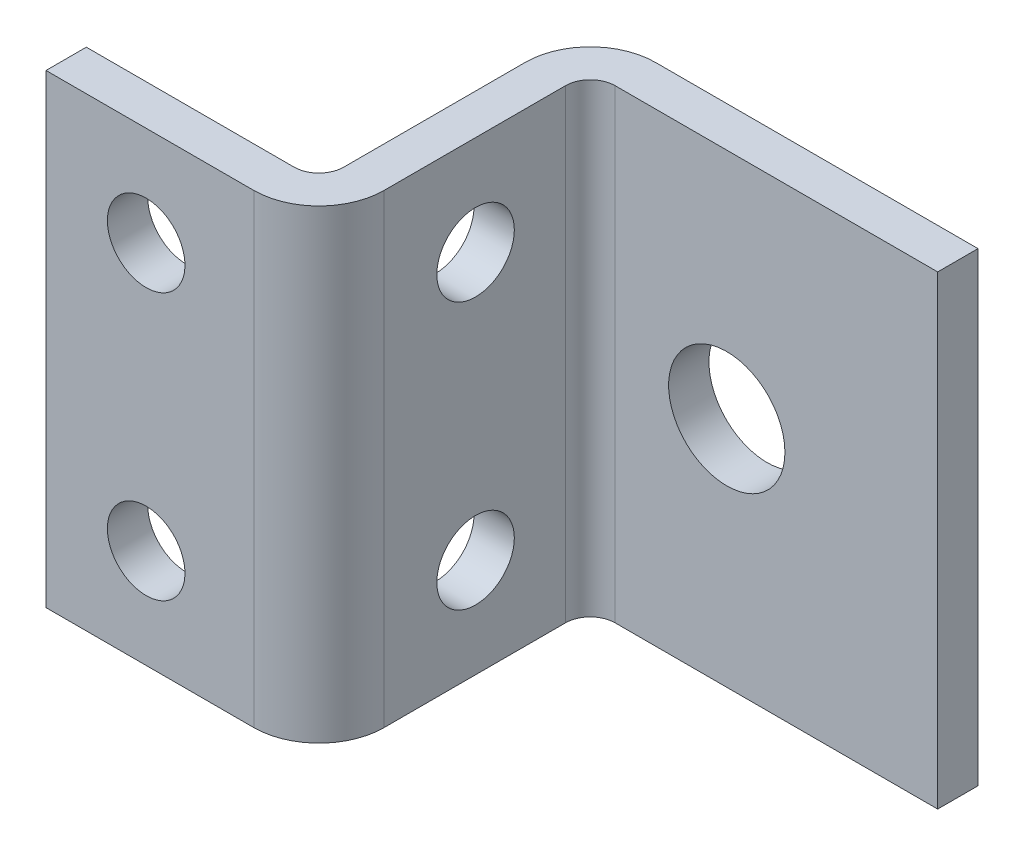
from build123d import *

# Parameters (mm, degrees)
EXTRUDE_THIN1_DEPTH = 19.05
SKETCH4_R           = 3.175
EXTRUDE3_DEPTH      = 26.527
SKETCH9_R           = 3.175
CUT_EXTRUDE3_DEPTH  = 23.352
SKETCH8_R           = 4.7625
CUT_EXTRUDE2_DEPTH  = 4.302


with BuildPart() as part:
    # Sketch1 → Extrude-Thin1 (new body, symmetric)
    with BuildSketch(Plane(origin=(0, 0, 0), x_dir=(1, 0, 0), z_dir=(0, 1, 0))):
        with BuildLine():
            Line((-19.05, -22.225), (-2.032, -22.225))
            ThreePointArc((-2.032, -22.225), (-0.595159021, -21.629840979), (0, -20.193))
            Line((0, -20.193), (0, -5.334))
            ThreePointArc((0, -5.334), (1.562292429, -1.562292429), (5.334, 0))
            Line((5.334, 0), (31.75, 0))
            Line((31.75, 0), (31.75, -3.302))
            Line((31.75, -3.302), (5.334, -3.302))
            ThreePointArc((5.334, -3.302), (3.897159021, -3.897159021), (3.302, -5.334))
            Line((3.302, -5.334), (3.302, -20.193))
            ThreePointArc((3.302, -20.193), (1.739707571, -23.964707571), (-2.032, -25.527))
            Line((-2.032, -25.527), (-19.05, -25.527))
            Line((-19.05, -25.527), (-19.05, -22.225))
        make_face()
    extrude(amount=EXTRUDE_THIN1_DEPTH, both=True)

    # Sketch4 → Extrude3 (cut, through all)
    with BuildSketch(Plane(origin=(-22.225, 0, 25.527), x_dir=(-1, 0, 0), z_dir=(0, 0, -1))):
        with Locations((-11.3792, 10.922)):
            Circle(SKETCH4_R)
        with Locations((-11.3792, -10.922)):
            Circle(SKETCH4_R)
    extrude(amount=EXTRUDE3_DEPTH, mode=Mode.SUBTRACT)

    # Sketch9 → Cut-Extrude3 (cut, through all)
    with BuildSketch(Plane(origin=(3.302, 0, 0), x_dir=(0, 0, -1), z_dir=(1, 0, 0))):
        with Locations((-12.7, 10.922)):
            Circle(SKETCH9_R)
        with Locations((-12.7, -10.922)):
            Circle(SKETCH9_R)
    extrude(amount=-CUT_EXTRUDE3_DEPTH, mode=Mode.SUBTRACT)

    # Sketch8 → Cut-Extrude2 (cut, through all)
    with BuildSketch(Plane.XY.offset(3.302)):
        with Locations((14.478, 0)):
            Circle(SKETCH8_R)
        with Locations((-55.372, 0)):
            Circle(SKETCH8_R)
    extrude(amount=-CUT_EXTRUDE2_DEPTH, mode=Mode.SUBTRACT)


solid = part.part
